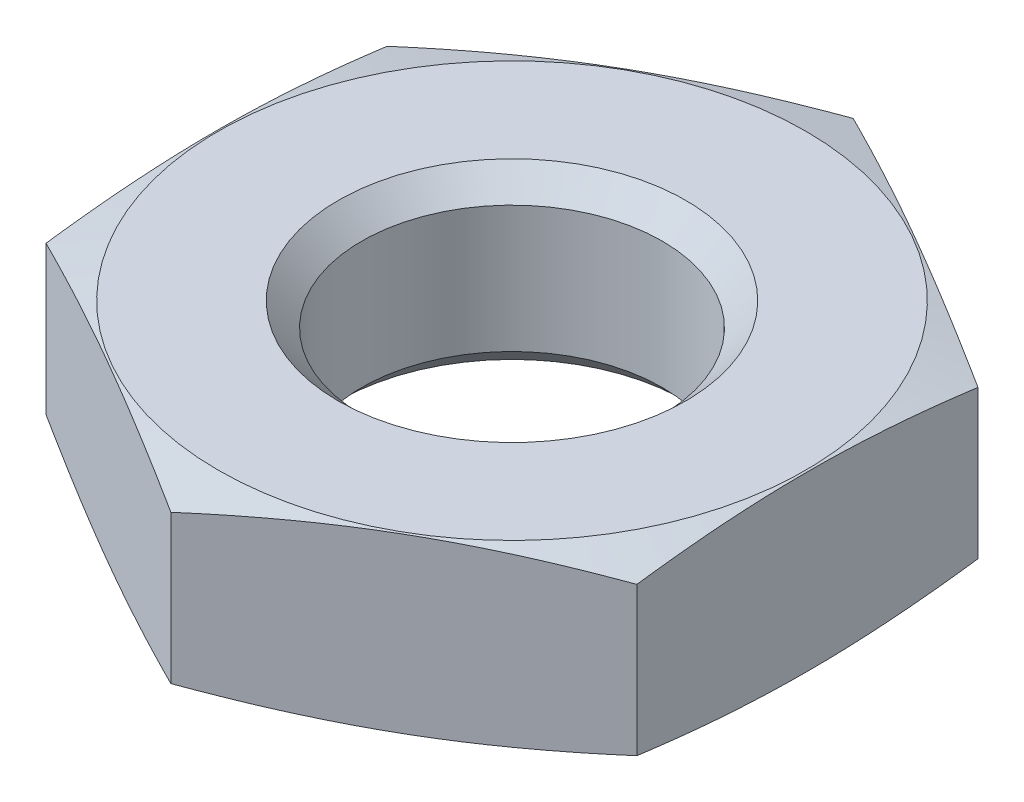
from build123d import *

# Parameters (mm, degrees)
SKETCH2_W               = 68
SKETCH2_H               = 68
CUT_EXTRUDE1_DEPTH      = 6
CUT_EXTRUDE1_DEPTH_BACK = 6


with BuildPart() as part:
    # Sketch1 → Revolve1 (revolve)
    with BuildSketch(Plane.XY):
        Polygon((0, 0), (8.45, 0), (17.780127019, -2.5), (8.45, -5), (0, -5), align=None)
    revolve(axis=Axis((0, -5, 0), (0, 1, 0)))

    # Sketch2 → Cut-Extrude1 (cut, two sides)
    with BuildSketch(Plane(origin=(0, 0, 0), x_dir=(1, 0, 0), z_dir=(0, 1, 0))) as cut_extrude1_sk:
        Rectangle(SKETCH2_W, SKETCH2_H)
        Polygon((-8.5, -4.907477288), (0, -9.814954576), (8.5, -4.907477288), (8.5, 4.907477288), (0, 9.814954576), (-8.5, 4.907477288), align=None, mode=Mode.SUBTRACT)
    extrude(amount=CUT_EXTRUDE1_DEPTH, mode=Mode.SUBTRACT)
    extrude(cut_extrude1_sk.sketch, amount=-CUT_EXTRUDE1_DEPTH_BACK, mode=Mode.SUBTRACT)

    # Sketch3 → Cut-Revolve1 (revolve, cut)
    with BuildSketch(Plane.XY):
        Polygon((0, 0), (5, 0), (4.3235, -0.6765), (4.3235, -4.3235), (5, -5), (0, -5), align=None)
    revolve(axis=Axis((0, -5, 0), (0, 1, 0)), mode=Mode.SUBTRACT)


solid = part.part
